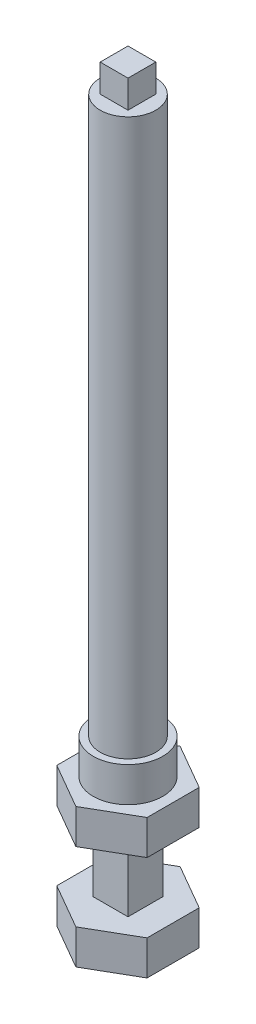
from build123d import *

# Parameters (mm, degrees)
SKETCH1_W           = 5
SKETCH1_H           = 5
BOSS_EXTRUDE1_DEPTH = 10
BOSS_EXTRUDE2_DEPTH = 5
BOSS_EXTRUDE3_DEPTH = 5
SKETCH4_R           = 5
BOSS_EXTRUDE4_DEPTH = 5
SKETCH5_R           = 4
BOSS_EXTRUDE5_DEPTH = 80
SKETCH6_W           = 4
SKETCH6_H           = 4
BOSS_EXTRUDE6_DEPTH = 4


with BuildPart() as part:
    # Sketch1 → Boss-Extrude1 (new body)
    with BuildSketch(Plane(origin=(0, 0, 0), x_dir=(1, 0, 0), z_dir=(0, 1, 0))):
        Rectangle(SKETCH1_W, SKETCH1_H)
    extrude(amount=BOSS_EXTRUDE1_DEPTH)

    # Sketch2 → Boss-Extrude2 (add)
    with BuildSketch(Plane.XZ):
        Polygon((0, 7.5), (-6.495190528, 3.75), (-6.495190528, -3.75), (0, -7.5), (6.495190528, -3.75), (6.495190528, 3.75), align=None)
    extrude(amount=BOSS_EXTRUDE2_DEPTH)

    # Sketch3 → Boss-Extrude3 (add)
    with BuildSketch(Plane(origin=(0, 10, 0), x_dir=(1, 0, 0), z_dir=(0, 1, 0))):
        Polygon((0, -7.5), (6.495190528, -3.75), (6.495190528, 3.75), (0, 7.5), (-6.495190528, 3.75), (-6.495190528, -3.75), align=None)
    extrude(amount=BOSS_EXTRUDE3_DEPTH)

    # Sketch4 → Boss-Extrude4 (add)
    with BuildSketch(Plane(origin=(0, 15, 0), x_dir=(1, 0, 0), z_dir=(0, 1, 0))):
        Circle(SKETCH4_R)
    extrude(amount=BOSS_EXTRUDE4_DEPTH)

    # Sketch5 → Boss-Extrude5 (add)
    with BuildSketch(Plane(origin=(0, 20, 0), x_dir=(1, 0, 0), z_dir=(0, 1, 0))):
        Circle(SKETCH5_R)
    extrude(amount=BOSS_EXTRUDE5_DEPTH)

    # Sketch6 → Boss-Extrude6 (add)
    with BuildSketch(Plane(origin=(0, 100, 0), x_dir=(1, 0, 0), z_dir=(0, 1, 0))):
        Rectangle(SKETCH6_W, SKETCH6_H)
    extrude(amount=BOSS_EXTRUDE6_DEPTH)


solid = part.part
